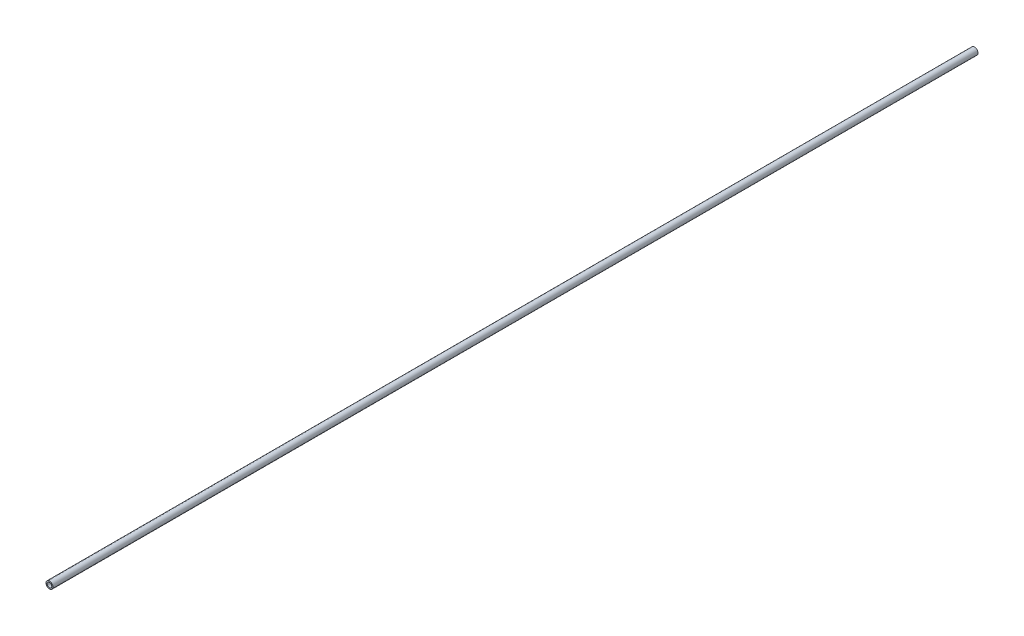
from build123d import *

# Parameters (mm, degrees)
SKETCH1_R           = 3
SKETCH1_R_2         = 2
BOSS_EXTRUDE1_DEPTH = 800


with BuildPart() as part:
    # Sketch1 → Boss-Extrude1 (new body)
    with BuildSketch(Plane.XY):
        Circle(SKETCH1_R)
        Circle(SKETCH1_R_2, mode=Mode.SUBTRACT)
    extrude(amount=BOSS_EXTRUDE1_DEPTH)


solid = part.part
